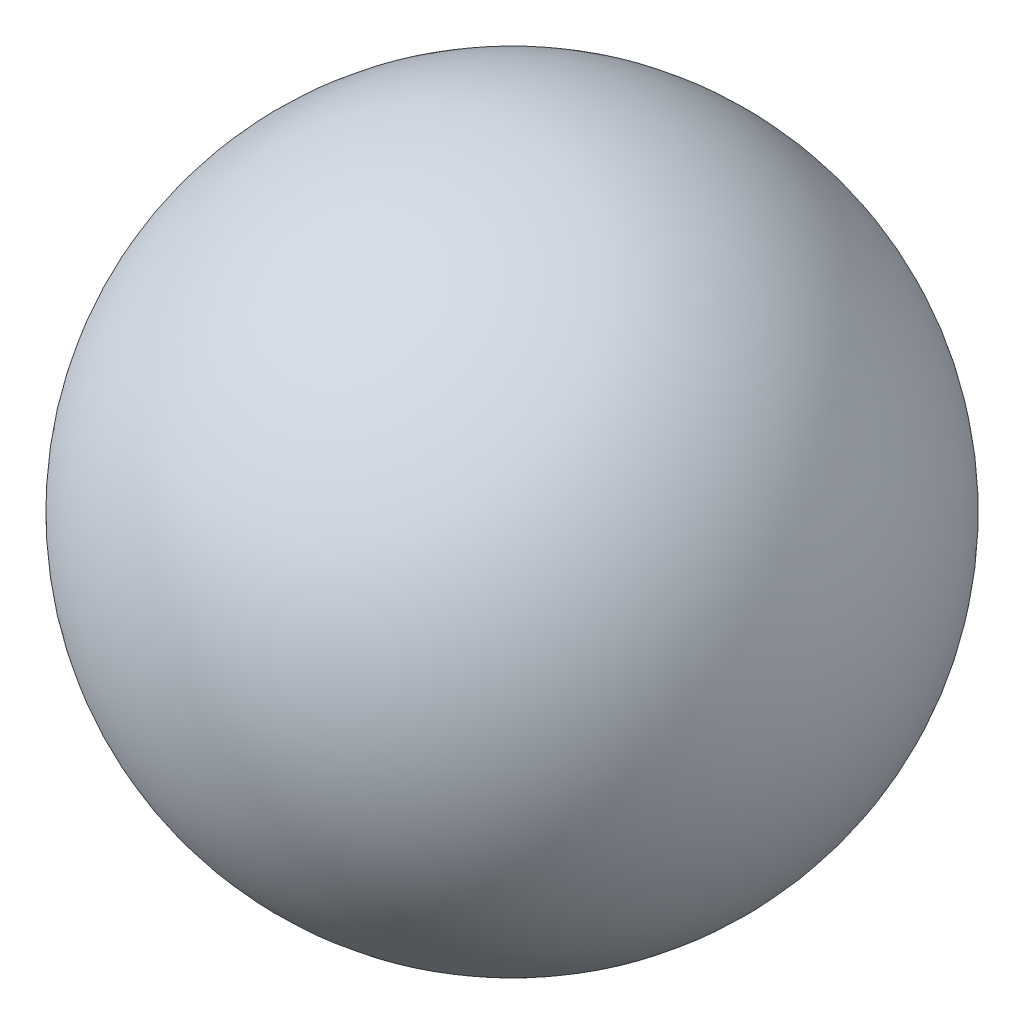
from build123d import *


with BuildPart() as part:
    # Sketch1 → Revolve5 (revolve)
    with BuildSketch(Plane.XY):
        with BuildLine():
            Line((0, -19.05), (0, 19.05))
            ThreePointArc((0, 19.05), (-19.05, 0), (0, -19.05))
        make_face()
    revolve(axis=Axis((0, 41.437879475, 0), (0, -1, 0)))


solid = part.part
